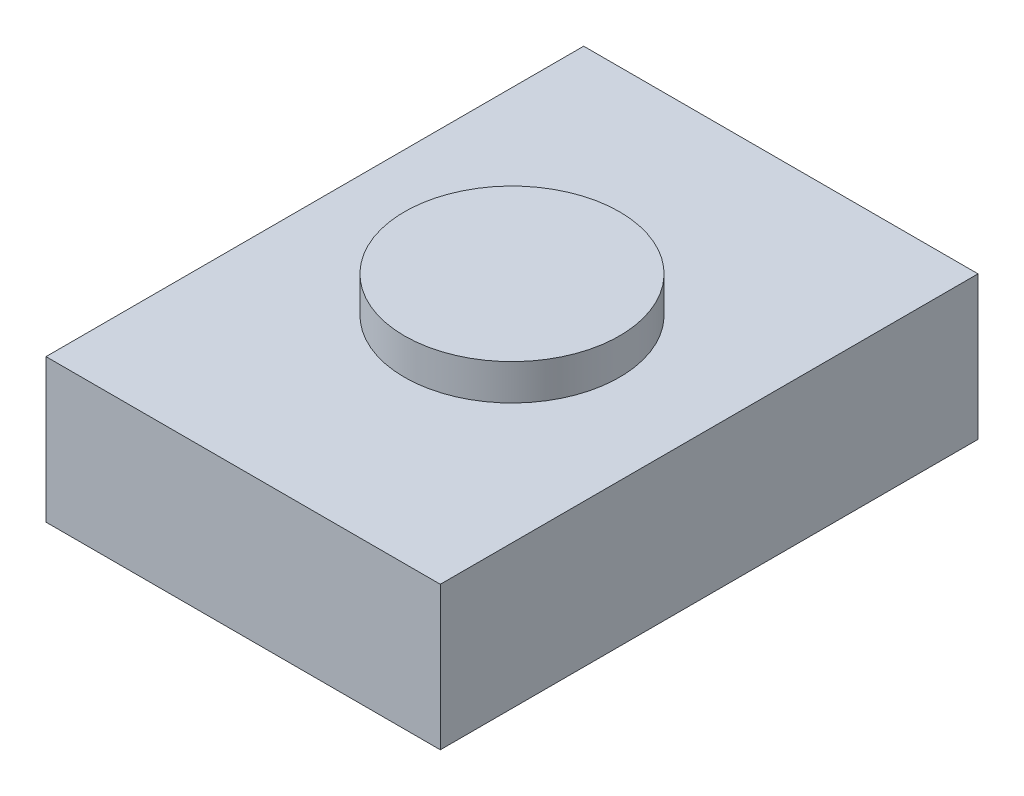
from build123d import *

# Parameters (mm, degrees)
SKETCH1_W           = 2.794
SKETCH1_H           = 3.81
BOSS_EXTRUDE1_DEPTH = 1.016
SKETCH2_R           = 0.762
BOSS_EXTRUDE2_DEPTH = 0.254


with BuildPart() as part:
    # Sketch1 → Boss-Extrude1 (new body)
    with BuildSketch(Plane(origin=(0, 0, 0), x_dir=(1, 0, 0), z_dir=(0, 1, 0))):
        Rectangle(SKETCH1_W, SKETCH1_H)
    extrude(amount=BOSS_EXTRUDE1_DEPTH)

    # Sketch2 → Boss-Extrude2 (add)
    with BuildSketch(Plane(origin=(0, 1.016, 0), x_dir=(1, 0, 0), z_dir=(0, 1, 0))):
        Circle(SKETCH2_R)
    extrude(amount=BOSS_EXTRUDE2_DEPTH)


solid = part.part
